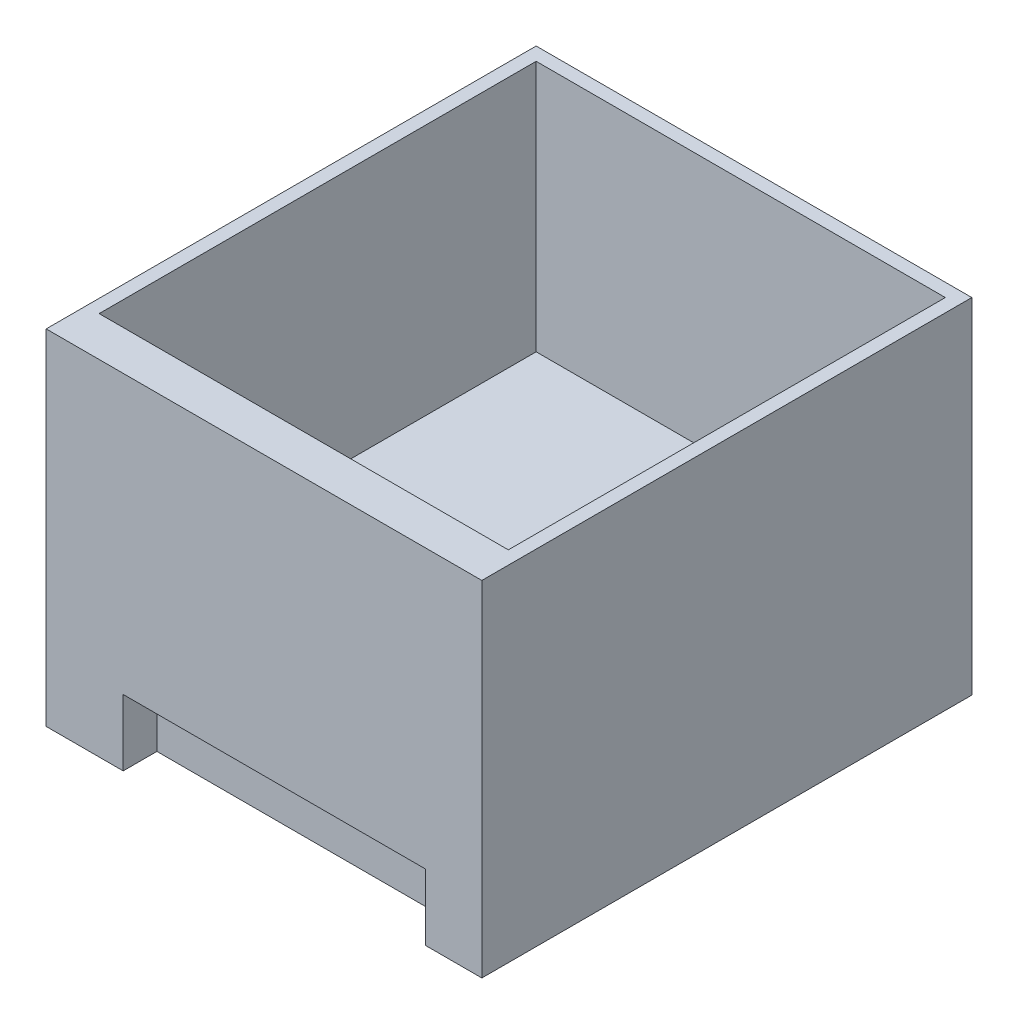
from build123d import *

# Parameters (mm, degrees)
ESQUISSE1_W             = 329
ESQUISSE1_H             = 260
BOSS_EXTRU_1_DEPTH      = 370
ESQUISSE2_W             = 309
ESQUISSE2_H             = 330
ENL_V_MAT_EXTRU_1_DEPTH = 190
ESQUISSE11_W            = 228.480314258
ESQUISSE11_H            = 25.470871893
ENL_V_MAT_EXTRU_9_DEPTH = 50


with BuildPart() as part:
    # Esquisse1 → Boss.-Extru.1 (new body)
    with BuildSketch(Plane.XY):
        with Locations((65.728262625, -82.519920319)):
            Rectangle(ESQUISSE1_W, ESQUISSE1_H)
    extrude(amount=-BOSS_EXTRU_1_DEPTH)

    # Esquisse2 → Enlèv. mat.-Extru.1 (cut)
    with BuildSketch(Plane(origin=(0, 47.480079681, 0), x_dir=(1, 0, 0), z_dir=(0, 1, 0))):
        with Locations((65.728262625, 195)):
            Rectangle(ESQUISSE2_W, ESQUISSE2_H)
    extrude(amount=-ENL_V_MAT_EXTRU_1_DEPTH, mode=Mode.SUBTRACT)

    # Esquisse11 → Enlèv. mat.-Extru.9 (cut)
    with BuildSketch(Plane(origin=(0, -212.519920319, 0), x_dir=(-1, 0, 0), z_dir=(0, -1, 0))):
        with Locations((-73.615667683, 12.735435947)):
            Rectangle(ESQUISSE11_W, ESQUISSE11_H)
    extrude(amount=-ENL_V_MAT_EXTRU_9_DEPTH, mode=Mode.SUBTRACT)


solid = part.part
